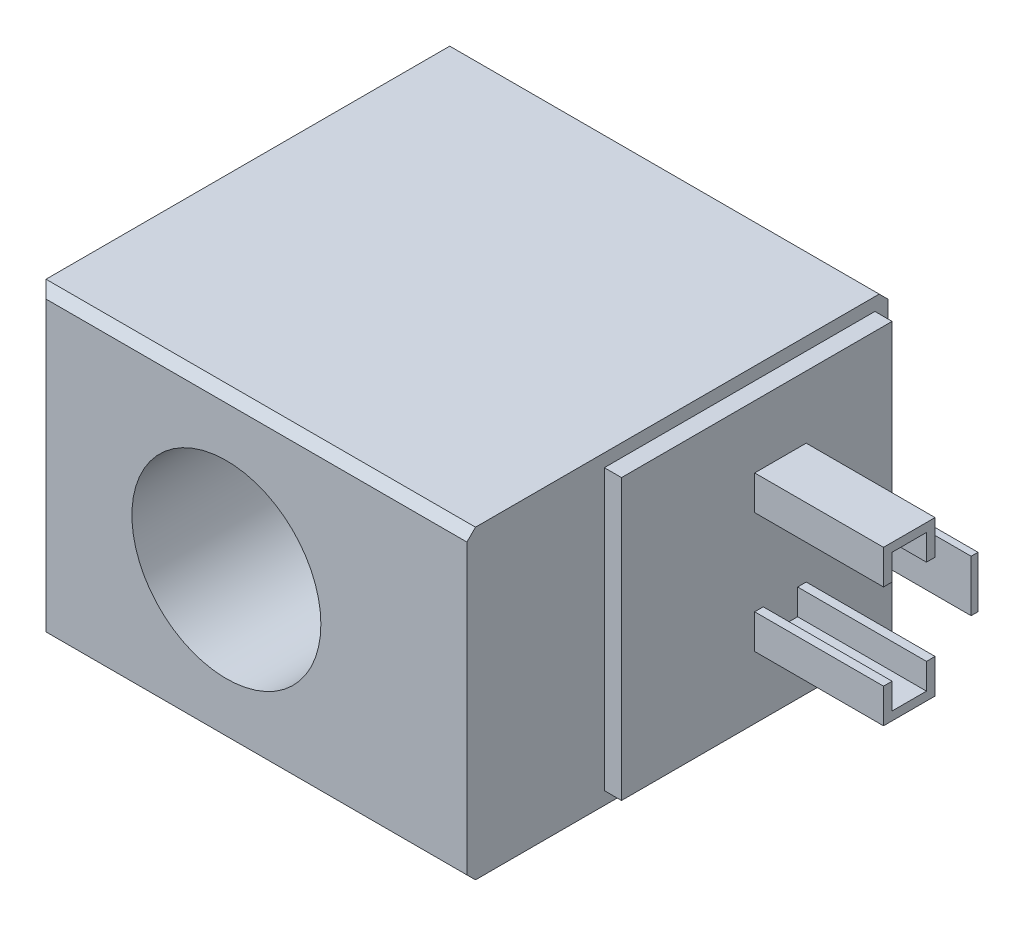
from build123d import *

# Parameters (mm, degrees)
SKETCH1_W           = 50
SKETCH1_H           = 35.56
SKETCH1_R           = 11
BOSS_EXTRUDE1_DEPTH = 49
SKETCH2_W           = 31.5
SKETCH2_H           = 32.56
BOSS_EXTRUDE2_DEPTH = 2
SKETCH3_W           = 0.8
SKETCH3_H           = 6
BOSS_EXTRUDE3_DEPTH = 15
CHAMFER1_SIZE       = 1


with BuildPart() as part:
    # Sketch1 → Boss-Extrude1 (new body)
    with BuildSketch(Plane.XY):
        Rectangle(SKETCH1_W, SKETCH1_H)
        with Locations((-3, 0)):
            Circle(SKETCH1_R, mode=Mode.SUBTRACT)
    extrude(amount=BOSS_EXTRUDE1_DEPTH)

    # Sketch2 → Boss-Extrude2 (add)
    with BuildSketch(Plane(origin=(25, 0, 0), x_dir=(0, 0, -1), z_dir=(1, 0, 0))):
        with Locations((-17.25, 0)):
            Rectangle(SKETCH2_W, SKETCH2_H)
    extrude(amount=BOSS_EXTRUDE2_DEPTH)

    # Sketch3 → Boss-Extrude3 (add)
    with BuildSketch(Plane(origin=(27, 0, 0), x_dir=(0, 0, -1), z_dir=(1, 0, 0))):
        Polygon((-16.5, 5), (-16.5, 8), (-12.5, 8), (-12.5, 5), (-11.5, 5), (-11.5, 9), (-17.5, 9), (-17.5, 5), align=None)
        with Locations((-6.9, 0)):
            Rectangle(SKETCH3_W, SKETCH3_H)
        Polygon((-12.5, -5), (-11.5, -5), (-11.5, -9), (-17.5, -9), (-17.5, -5), (-16.5, -5), (-16.5, -8), (-12.5, -8), align=None)
    extrude(amount=BOSS_EXTRUDE3_DEPTH)

    # Chamfer1
    chamfer1_edges = [part.edges().sort_by_distance(p)[0] for p in [
        (0, 17.78, 49),
        (-25, 0, 49),
        (0, 17.78, 0),
        (0, -17.78, 0),
        (-25, 0, 0),
        (0, -17.78, 49),
    ]]
    chamfer(chamfer1_edges, length=CHAMFER1_SIZE)


solid = part.part
